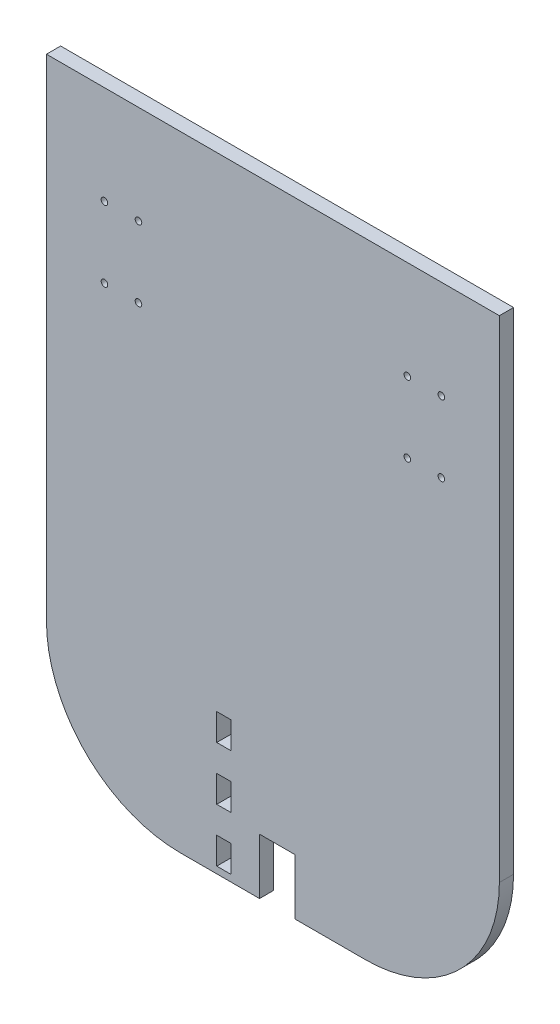
from build123d import *

# Parameters (mm, degrees)
SKETCH1_W           = 203
SKETCH1_H           = 280
BOSS_EXTRUDE1_DEPTH = 6.35
SKETCH2_R           = 1.475
CUT_EXTRUDE1_DEPTH  = 6.35
SKETCH3_W           = 6.35
SKETCH3_H           = 12
SKETCH3_W_2         = 16
SKETCH3_H_2         = 25
CUT_EXTRUDE2_DEPTH  = 6.35
FILLET1_R           = 60


with BuildPart() as part:
    # Sketch1 → Boss-Extrude1 (new body)
    with BuildSketch(Plane.XY):
        Rectangle(SKETCH1_W, SKETCH1_H)
    extrude(amount=BOSS_EXTRUDE1_DEPTH)

    # Sketch2 → Cut-Extrude1 (cut)
    with BuildSketch(Plane.XY.offset(6.35)):
        with Locations((60.26, 95.875)):
            Circle(SKETCH2_R)
        with Locations((75.5, 95.875)):
            Circle(SKETCH2_R)
        with Locations((60.26, 64.125)):
            Circle(SKETCH2_R)
        with Locations((75.5, 64.125)):
            Circle(SKETCH2_R)
        with Locations((-75.5, 64.125)):
            Circle(SKETCH2_R)
        with Locations((-60.26, 64.125)):
            Circle(SKETCH2_R)
        with Locations((-75.5, 95.875)):
            Circle(SKETCH2_R)
        with Locations((-60.26, 95.875)):
            Circle(SKETCH2_R)
    extrude(amount=-CUT_EXTRUDE1_DEPTH, mode=Mode.SUBTRACT)

    # Sketch3 → Cut-Extrude2 (cut)
    with BuildSketch(Plane.XY.offset(6.35)):
        with Locations((-22, -131)):
            Rectangle(SKETCH3_W, SKETCH3_H)
        with Locations((-22, -107)):
            Rectangle(SKETCH3_W, SKETCH3_H)
        with Locations((-22, -83)):
            Rectangle(SKETCH3_W, SKETCH3_H)
        with Locations((2, -127.5)):
            Rectangle(SKETCH3_W_2, SKETCH3_H_2)
    extrude(amount=-CUT_EXTRUDE2_DEPTH, mode=Mode.SUBTRACT)

    # Fillet1
    fillet1_edges = [part.edges().sort_by_distance(p)[0] for p in [
        (101.5, -140, 3.175),
        (-101.5, -140, 3.175),
    ]]
    fillet(fillet1_edges, radius=FILLET1_R)


solid = part.part
